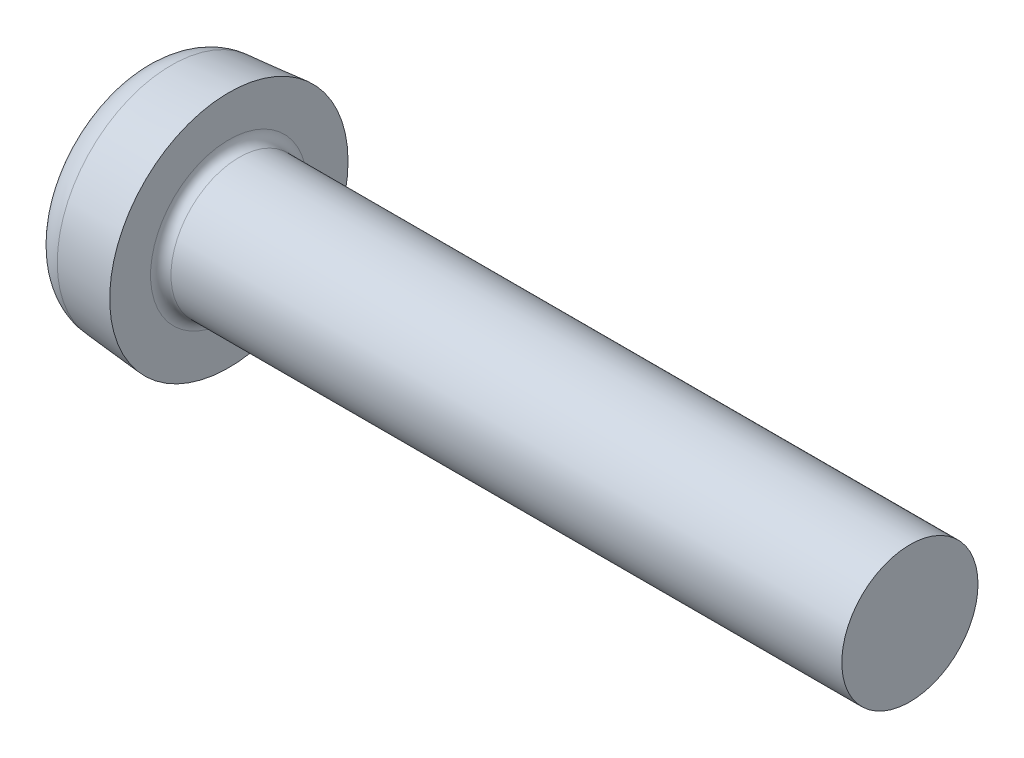
from build123d import *

# Parameters (mm, degrees)
CROSSRECESS_DEPTH = 2.6
FILLET5_R         = 0.3
HEADFILLET_R      = 1
DRAFT1_ANGLE      = 20


with BuildPart() as part:
    # Sketch1 → Base (revolve)
    with BuildSketch(Plane.XY):
        with BuildLine():
            Line((22.6, 2), (4, 2))
            Line((4, 2), (2.9, 2))
            ThreePointArc((2.9, 2), (2.687867966, 2.087867966), (2.6, 2.3))
            Line((2.6, 2.3), (2.6, 3.5))
            Line((2.6, 3.5), (0, 3.272529475))
            Line((0, 3.272529475), (0, 0))
            Line((0, 0), (22.6, 0))
            Line((22.6, 0), (22.6, 2))
        make_face()
    revolve(axis=Axis((4.515812911, 0, 0), (-1, 0, 0)))

    # Sketch6 → CrossRecess (cut)
    with BuildSketch(Plane(origin=(0, 0, 0), x_dir=(0, 0, -1), z_dir=(1, 0, 0))):
        Polygon((0.41, 0.41), (0.41, 2.05), (-0.41, 2.05), (-0.41, 0.41), (-2.05, 0.41), (-2.05, -0.41), (-0.41, -0.41), (-0.41, -2.05), (0.41, -2.05), (0.41, -0.41), (2.05, -0.41), (2.05, 0.41), align=None)
    extrude(amount=CROSSRECESS_DEPTH, mode=Mode.SUBTRACT)

    # Fillet5
    fillet5_edges = [part.edges().sort_by_distance(p)[0] for p in [
        (1.3, 0.41, 0.41),
        (1.3, -0.41, 0.41),
        (1.3, -0.41, -0.41),
        (1.3, 0.41, -0.41),
    ]]
    fillet(fillet5_edges, radius=FILLET5_R)

    # HeadFillet
    headfillet_edges = [part.edges().sort_by_distance(p)[0] for p in [
        (0, -3.272529475, 0),
    ]]
    fillet(headfillet_edges, radius=HEADFILLET_R)

    # Draft1
    draft1_faces = [part.faces().sort_by_distance(p)[0] for p in [
        (1.3, 0, 2.05),
        (1.3, -2.05, 0),
        (1.3, 0, -2.05),
        (1.3, 2.05, 0),
    ]]
    draft(draft1_faces, Plane(origin=(0, 0, 0), x_dir=(0, 0, -1), z_dir=(-1, 0, 0)), DRAFT1_ANGLE)


solid = part.part
